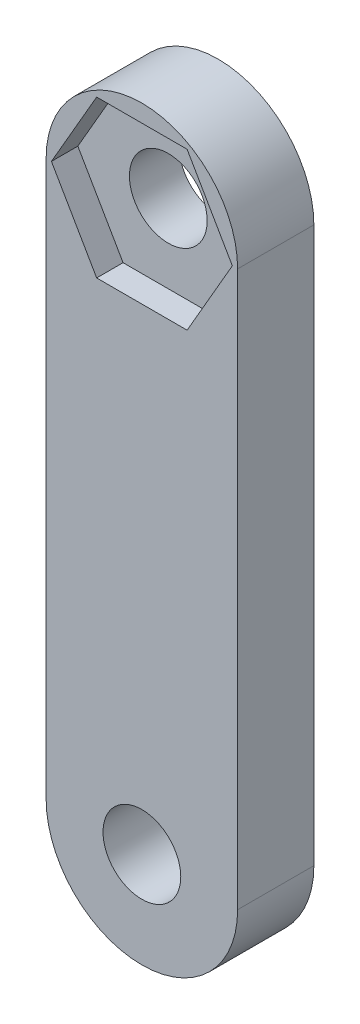
from build123d import *

# Parameters (mm, degrees)
SKETCH1_R           = 3.2385
BOSS_EXTRUDE1_DEPTH = 6.35
CUT_EXTRUDE1_DEPTH  = 2.2


with BuildPart() as part:
    # Sketch1 → Boss-Extrude1 (new body)
    with BuildSketch(Plane.XY):
        with BuildLine():
            Line((7.9756, 23.114), (7.9756, -23.114))
            ThreePointArc((7.9756, -23.114), (0, -31.0896), (-7.9756, -23.114))
            Line((-7.9756, -23.114), (-7.9756, 23.114))
            ThreePointArc((-7.9756, 23.114), (0, 31.0896), (7.9756, 23.114))
        make_face()
        with Locations((0, 23.114)):
            Circle(SKETCH1_R, mode=Mode.SUBTRACT)
        with Locations((0, -23.114)):
            Circle(SKETCH1_R, mode=Mode.SUBTRACT)
    extrude(amount=BOSS_EXTRUDE1_DEPTH)

    # Sketch2 → Cut-Extrude1 (cut)
    with BuildSketch(Plane.XY.offset(6.35)):
        Polygon((-7.534421013, 23.114), (-3.767210506, 16.589), (3.767210506, 16.589), (7.534421013, 23.114), (3.767210506, 29.639), (-3.767210506, 29.639), align=None)
    extrude(amount=-CUT_EXTRUDE1_DEPTH, mode=Mode.SUBTRACT)


solid = part.part
